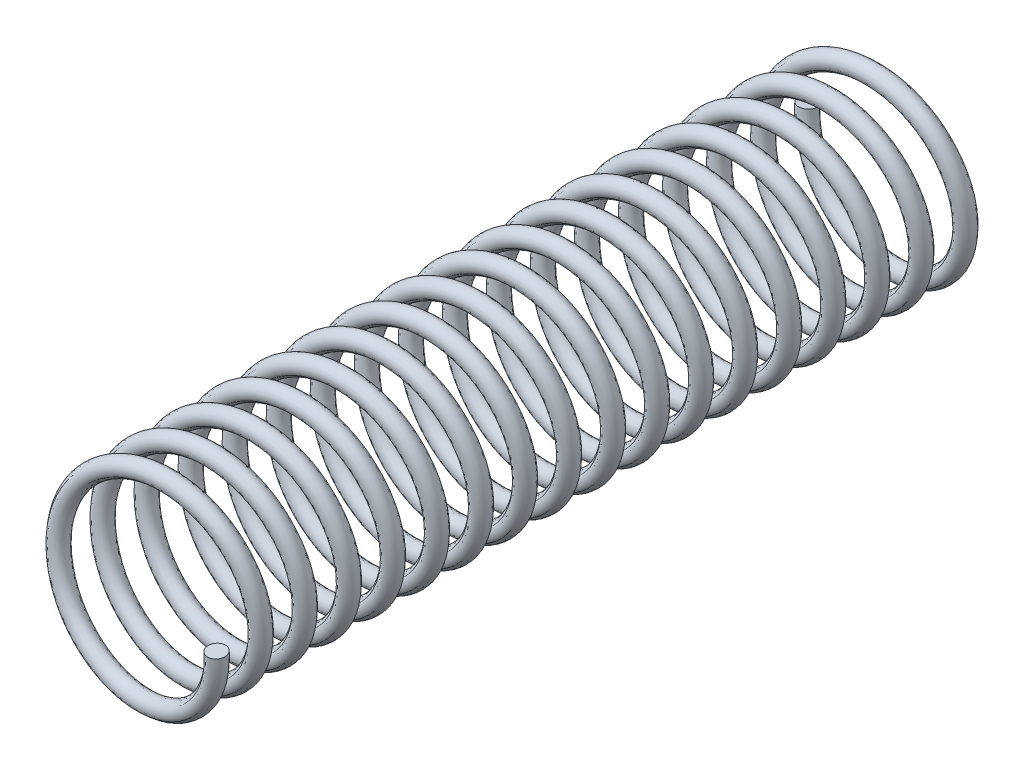
from build123d import *

# Parameters (mm, degrees)
SWEEP1_PITCH       = 0.972457143
SWEEP1_HEIGHT      = 17.018
SWEEP1_RADIUS      = 1.984375
SWEEP1_START_ANGLE = 180
SKETCH3_R          = 0.1984375


with BuildPart() as part:
    # Sweep1: sweep along a helix
    with BuildLine() as sweep1_path:
        add(Helix(SWEEP1_PITCH, SWEEP1_HEIGHT, SWEEP1_RADIUS, center=(0, 0, 0), direction=(0, 0, -1), mode=Mode.PRIVATE).rotate(Axis((0, 0, 0), (0, 0, -1)), SWEEP1_START_ANGLE))
    # Sketch3 → Sweep1 (sweep)
    with BuildSketch(Plane(origin=(1.984375, 0, 0), x_dir=(-1, 0, 0), z_dir=(0, -0.996972196, -0.077758863))):
        with Locations((-0.000271486, 0)):
            Circle(SKETCH3_R)
    sweep(path=sweep1_path.line, is_frenet=True)


solid = part.part
